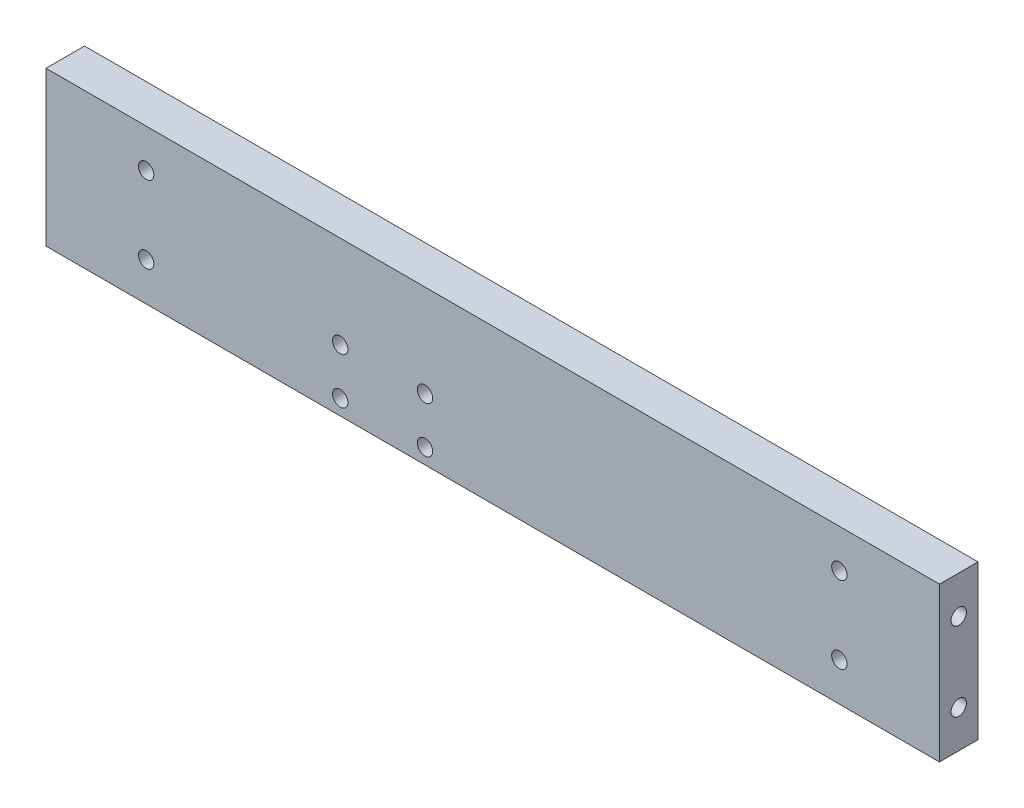
from build123d import *

# Parameters (mm, degrees)
SKETCH1_W           = 116
SKETCH1_H           = 20
BOSS_EXTRUDE2_DEPTH = 5
SKETCH4_R           = 1
CUT_EXTRUDE1_DEPTH  = 10
SKETCH6_R           = 1
CUT_EXTRUDE2_DEPTH  = 5
SKETCH7_R           = 1
CUT_EXTRUDE3_DEPTH  = 6
SKETCH8_R           = 1
CUT_EXTRUDE4_DEPTH  = 6


with BuildPart() as part:
    # Sketch1 → Boss-Extrude2 (new body)
    with BuildSketch(Plane.XY):
        Rectangle(SKETCH1_W, SKETCH1_H)
    extrude(amount=BOSS_EXTRUDE2_DEPTH)

    # Sketch4 → Cut-Extrude1 (cut)
    with BuildSketch(Plane(origin=(58, 0, 0), x_dir=(0, 0, -1), z_dir=(1, 0, 0))):
        with Locations((-2.5, -5.12)):
            Circle(SKETCH4_R)
        with Locations((-2.5, 5.12)):
            Circle(SKETCH4_R)
    extrude(amount=-CUT_EXTRUDE1_DEPTH, mode=Mode.SUBTRACT)

    # Sketch6 → Cut-Extrude2 (cut)
    with BuildSketch(Plane.ZY.offset(58)):
        with Locations((2.5, 5)):
            Circle(SKETCH6_R)
        with Locations((2.5, -5)):
            Circle(SKETCH6_R)
    extrude(amount=-CUT_EXTRUDE2_DEPTH, mode=Mode.SUBTRACT)

    # Sketch7 → Cut-Extrude3 (cut, through all)
    with BuildSketch(Plane(origin=(0, 0, 0), x_dir=(-1, 0, 0), z_dir=(0, 0, -1))):
        with Locations((-45, 5)):
            Circle(SKETCH7_R)
        with Locations((-45, -5)):
            Circle(SKETCH7_R)
        with Locations((45, 5)):
            Circle(SKETCH7_R)
        with Locations((45, -5)):
            Circle(SKETCH7_R)
    extrude(amount=-CUT_EXTRUDE3_DEPTH, mode=Mode.SUBTRACT)

    # Sketch8 → Cut-Extrude4 (cut, through all)
    with BuildSketch(Plane(origin=(0, 0, 0), x_dir=(-1, 0, 0), z_dir=(0, 0, -1))):
        with Locations((19.8, -8)):
            Circle(SKETCH8_R)
        with Locations((19.8, -2)):
            Circle(SKETCH8_R)
        with Locations((8.8, -2)):
            Circle(SKETCH8_R)
        with Locations((8.8, -8)):
            Circle(SKETCH8_R)
    extrude(amount=-CUT_EXTRUDE4_DEPTH, mode=Mode.SUBTRACT)


solid = part.part
